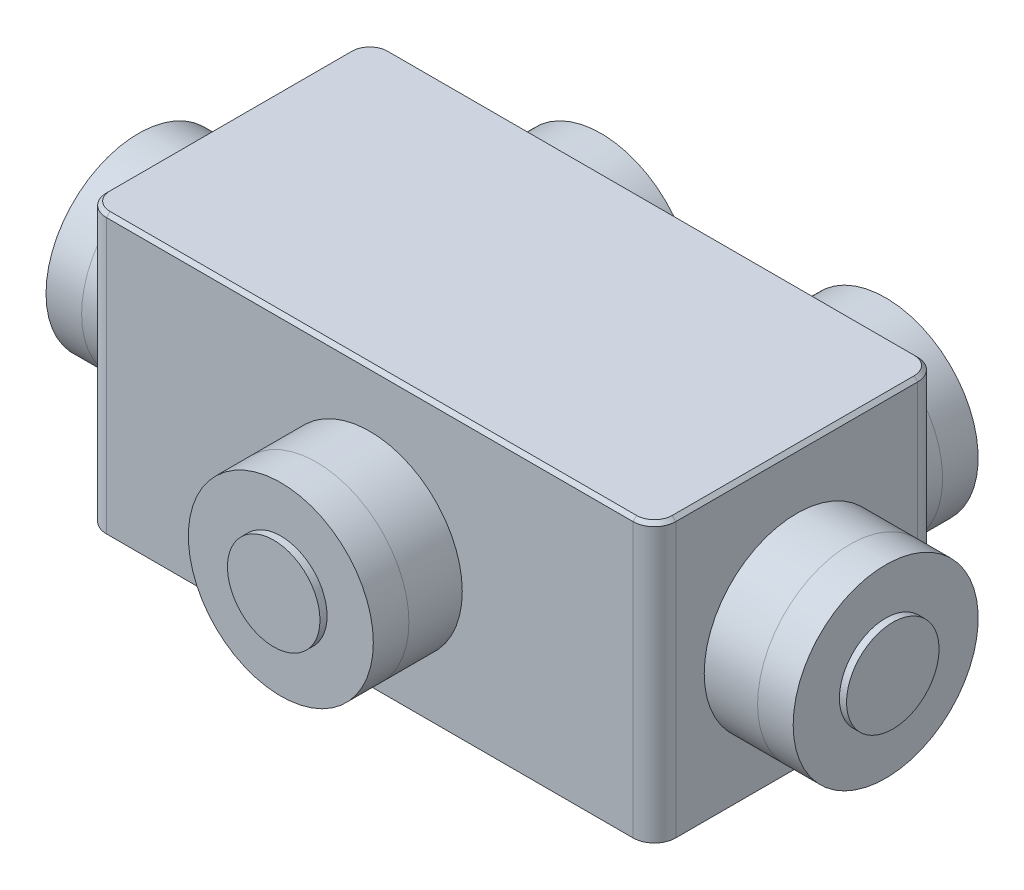
from build123d import *

# Parameters (mm, degrees)
BOSS_EXTRUDE1_DEPTH  = 39
CHAMFER1_SIZE        = 0.5
SKETCH2_R            = 13
BOSS_EXTRUDE2_DEPTH  = 7.5
SKETCH3_R            = 13
BOSS_EXTRUDE3_DEPTH  = 5
SKETCH4_R            = 6.5
BOSS_EXTRUDE4_DEPTH  = 1
SKETCH11_R           = 13
BOSS_EXTRUDE9_DEPTH  = 7.5
SKETCH13_R           = 13
BOSS_EXTRUDE10_DEPTH = 5
SKETCH15_R           = 6.5
BOSS_EXTRUDE11_DEPTH = 1
SKETCH25_R           = 13
BOSS_EXTRUDE16_DEPTH = 7.5
SKETCH27_R           = 13
BOSS_EXTRUDE17_DEPTH = 5
SKETCH29_R           = 6.5
BOSS_EXTRUDE18_DEPTH = 1
SKETCH39_R           = 13
BOSS_EXTRUDE23_DEPTH = 7.5
SKETCH41_R           = 13
BOSS_EXTRUDE24_DEPTH = 5
SKETCH43_R           = 6.5
BOSS_EXTRUDE25_DEPTH = 1
SKETCH59_R           = 5
BOSS_EXTRUDE30_DEPTH = 5
CHAMFER5_SIZE        = 1


with BuildPart() as part:
    # Sketch1 → Boss-Extrude1 (new body)
    with BuildSketch(Plane(origin=(0, 0, 0), x_dir=(1, 0, 0), z_dir=(0, 1, 0))):
        with BuildLine():
            Line((-37, -20), (37, -20))
            ThreePointArc((37, -20), (39.121320344, -19.121320344), (40, -17))
            Line((40, -17), (40, 17))
            ThreePointArc((40, 17), (39.121320344, 19.121320344), (37, 20))
            Line((37, 20), (-37, 20))
            ThreePointArc((-37, 20), (-39.121320344, 19.121320344), (-40, 17))
            Line((-40, 17), (-40, -17))
            ThreePointArc((-40, -17), (-39.121320344, -19.121320344), (-37, -20))
        make_face()
    extrude(amount=BOSS_EXTRUDE1_DEPTH)

    # Chamfer1
    chamfer1_edges = [part.edges().sort_by_distance(p)[0] for p in [
        (39.121320344, 39, -19.121320344),
        (0, 39, -20),
        (-39.121320344, 39, -19.121320344),
        (-40, 39, 0),
        (-39.121320344, 39, 19.121320344),
        (0, 39, 20),
        (39.121320344, 39, 19.121320344),
        (40, 39, 0),
    ]]
    chamfer(chamfer1_edges, length=CHAMFER1_SIZE)


with BuildPart() as body_2:
    # Sketch2 → Boss-Extrude2 (new body)
    with BuildSketch(Plane.ZY.offset(40)):
        with Locations((0, 18)):
            Circle(SKETCH2_R)
    extrude(amount=BOSS_EXTRUDE2_DEPTH)


with BuildPart() as body_3:
    # Sketch3 → Boss-Extrude3 (new body)
    with BuildSketch(Plane.ZY.offset(47.5)):
        with Locations((0, 18)):
            Circle(SKETCH3_R)
    extrude(amount=BOSS_EXTRUDE3_DEPTH)

    # Sketch4 → Boss-Extrude4 (add)
    with BuildSketch(Plane.ZY.offset(52.5)):
        with Locations((0, 18)):
            Circle(SKETCH4_R)
    extrude(amount=BOSS_EXTRUDE4_DEPTH)


with BuildPart() as body_4:
    # Mirror2: mirrored copy
    add(body_3.part.mirror(Plane(origin=(0, 0, 0), x_dir=(0, 0, 1), z_dir=(1, 0, 0))))


with BuildPart() as body_5:
    # Mirror2 2: mirrored copy
    add(body_2.part.mirror(Plane(origin=(0, 0, 0), x_dir=(0, 0, 1), z_dir=(1, 0, 0))))


with BuildPart() as body_6:
    # Sketch11 → Boss-Extrude9 (new body)
    with BuildSketch(Plane(origin=(-15.219675371, -9.618672718, 20), x_dir=(1, 0, 0), z_dir=(0, 0, 1))):
        with Locations((15.219675371, 27.618672718)):
            Circle(SKETCH11_R)
    extrude(amount=BOSS_EXTRUDE9_DEPTH)


with BuildPart() as body_7:
    # Sketch13 → Boss-Extrude10 (new body)
    with BuildSketch(Plane(origin=(-15.219675371, -9.618672718, 27.5), x_dir=(1, 0, 0), z_dir=(0, 0, 1))):
        with Locations((15.219675371, 27.618672718)):
            Circle(SKETCH13_R)
    extrude(amount=BOSS_EXTRUDE10_DEPTH)

    # Sketch15 → Boss-Extrude11 (add)
    with BuildSketch(Plane(origin=(-15.219675371, -9.618672718, 32.5), x_dir=(1, 0, 0), z_dir=(0, 0, 1))):
        with Locations((15.219675371, 27.618672718)):
            Circle(SKETCH15_R)
    extrude(amount=BOSS_EXTRUDE11_DEPTH)


with BuildPart() as body_8:
    # Sketch25 → Boss-Extrude16 (new body)
    with BuildSketch(Plane(origin=(-4.430271092, 5.776930412, -20), x_dir=(-1, 0, 0), z_dir=(0, 0, -1))):
        with Locations((15.569728908, 12.223069588)):
            Circle(SKETCH25_R)
    extrude(amount=BOSS_EXTRUDE16_DEPTH)


with BuildPart() as body_9:
    # Sketch27 → Boss-Extrude17 (new body)
    with BuildSketch(Plane(origin=(-4.430271092, 5.776930412, -27.5), x_dir=(-1, 0, 0), z_dir=(0, 0, -1))):
        with Locations((15.569728908, 12.223069588)):
            Circle(SKETCH27_R)
    extrude(amount=BOSS_EXTRUDE17_DEPTH)

    # Sketch29 → Boss-Extrude18 (add)
    with BuildSketch(Plane(origin=(-4.430271092, 5.776930412, -32.5), x_dir=(-1, 0, 0), z_dir=(0, 0, -1))):
        with Locations((15.569728908, 12.223069588)):
            Circle(SKETCH29_R)
    extrude(amount=BOSS_EXTRUDE18_DEPTH)


with BuildPart() as body_10:
    # Sketch39 → Boss-Extrude23 (new body)
    with BuildSketch(Plane(origin=(-17.91556365, -3.403900427, -20), x_dir=(-1, 0, 0), z_dir=(0, 0, -1))):
        with Locations((-37.91556365, 21.403900427)):
            Circle(SKETCH39_R)
    extrude(amount=BOSS_EXTRUDE23_DEPTH)


with BuildPart() as body_11:
    # Sketch41 → Boss-Extrude24 (new body)
    with BuildSketch(Plane(origin=(-17.91556365, -3.403900427, -27.5), x_dir=(-1, 0, 0), z_dir=(0, 0, -1))):
        with Locations((-37.91556365, 21.403900427)):
            Circle(SKETCH41_R)
    extrude(amount=BOSS_EXTRUDE24_DEPTH)

    # Sketch43 → Boss-Extrude25 (add)
    with BuildSketch(Plane(origin=(-17.91556365, -3.403900427, -32.5), x_dir=(-1, 0, 0), z_dir=(0, 0, -1))):
        with Locations((-37.91556365, 21.403900427)):
            Circle(SKETCH43_R)
    extrude(amount=BOSS_EXTRUDE25_DEPTH)


with BuildPart() as body_12:
    # Sketch59 → Boss-Extrude30 (new body)
    with BuildSketch(Plane(origin=(0, 0, -20), x_dir=(-1, 0, 0), z_dir=(0, 0, -1))):
        with Locations((0, 18)):
            Circle(SKETCH59_R)
    extrude(amount=BOSS_EXTRUDE30_DEPTH)

    # Chamfer5
    chamfer5_edges = [body_12.edges().sort_by_distance(p)[0] for p in [
        (5, 18, -25),
    ]]
    chamfer(chamfer5_edges, length=CHAMFER5_SIZE)


solid = Compound([part.part, body_2.part, body_3.part, body_4.part, body_5.part, body_6.part, body_7.part, body_8.part, body_9.part, body_10.part, body_11.part, body_12.part])
